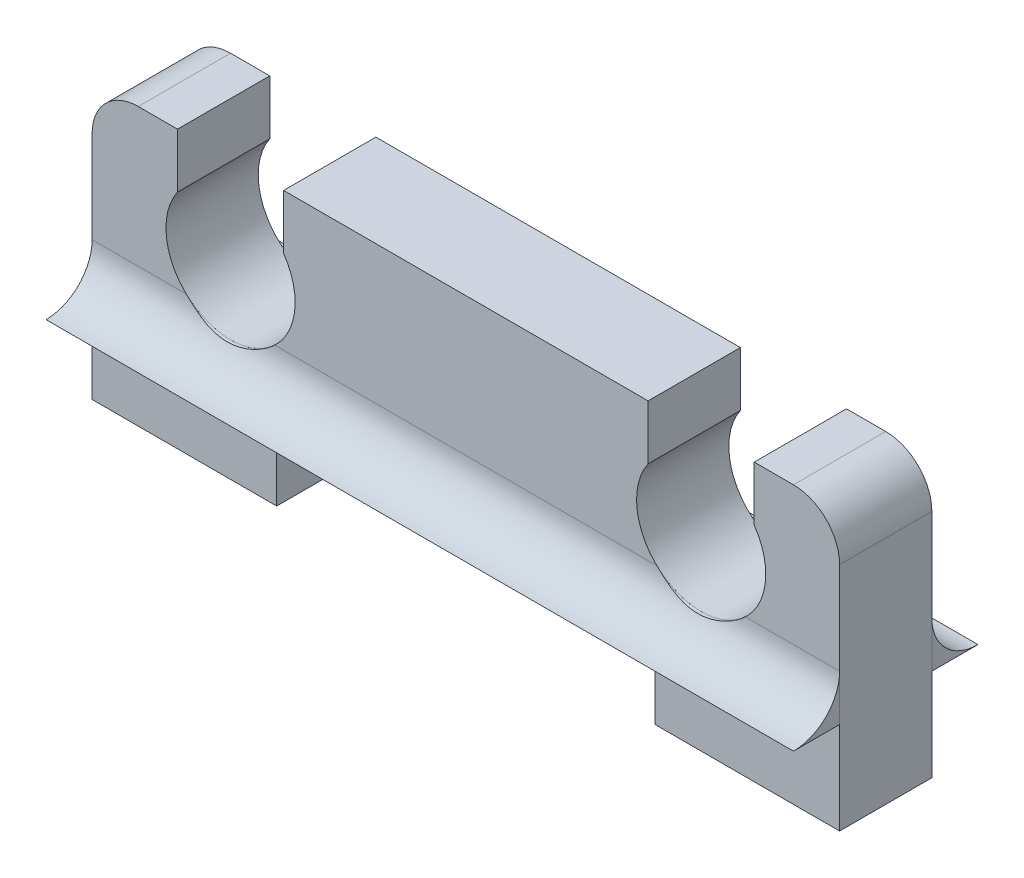
from build123d import *

# Parameters (mm, degrees)
BOSS_EXTRUDE1_DEPTH     = 2
BOSS_EXTRUDE2_DEPTH     = 16.2
BOSS_EXTRUDE2_2_DEPTH   = 16.2
SKETCH3_W               = 4
SKETCH3_H               = 2
CUT_EXTRUDE1_DEPTH      = 4
CUT_EXTRUDE4_START      = -1.18136
SKETCH5_W               = 2.3
SKETCH5_H               = 2
CUT_EXTRUDE4_DEPTH      = 1.18136
SKETCH8_R               = 1.4
CUT_EXTRUDE6_DEPTH      = 3
CUT_EXTRUDE6_DEPTH_BACK = 3


with BuildPart() as part:
    # Sketch1 → Boss-Extrude1 (new body)
    with BuildSketch(Plane.XY):
        with BuildLine():
            Line((4, 8), (12.2, 8))
            Line((12.2, 8), (12.2, 7))
            ThreePointArc((12.2, 7), (13.2, 4.620204103), (14.2, 7))
            Line((14.2, 7), (14.2, 8))
            Line((14.2, 8), (15.2, 8))
            ThreePointArc((15.2, 8), (15.907106781, 7.707106781), (16.2, 7))
            Line((16.2, 7), (16.2, 0))
            Line((16.2, 0), (12.2, 0))
            Line((12.2, 0), (12.2, 4))
            Line((12.2, 4), (4, 4))
            Line((4, 4), (4, 0))
            Line((4, 0), (0, 0))
            Line((0, 0), (0, 7))
            ThreePointArc((0, 7), (0.292893219, 7.707106781), (1, 8))
            Line((1, 8), (2, 8))
            Line((2, 8), (2, 7))
            ThreePointArc((2, 7), (3, 4.620204103), (4, 7))
            Line((4, 7), (4, 8))
        make_face()
    extrude(amount=BOSS_EXTRUDE1_DEPTH)

    # Sketch3 → Cut-Extrude1 (cut, through all)
    with BuildSketch(Plane.XY.offset(2)):
        with Locations((2, 1)):
            Rectangle(SKETCH3_W, SKETCH3_H)
        with Locations((14.2, 1)):
            Rectangle(SKETCH3_W, SKETCH3_H)
    extrude(amount=-CUT_EXTRUDE1_DEPTH, mode=Mode.SUBTRACT)

    # Sketch5 → Cut-Extrude4 (cut)
    with BuildSketch(Plane(origin=(0, 8, 0), x_dir=(1, 0, 0), z_dir=(0, 1, 0)).offset(CUT_EXTRUDE4_START)):
        with Locations((3, -1)):
            Rectangle(SKETCH5_W, SKETCH5_H)
        with Locations((13.2, -1)):
            Rectangle(SKETCH5_W, SKETCH5_H)
    extrude(amount=CUT_EXTRUDE4_DEPTH, mode=Mode.SUBTRACT)


with BuildPart() as body_2:
    # Sketch2 → Boss-Extrude2 (new body)
    with BuildSketch(Plane.ZY):
        with BuildLine():
            Line((2, 4), (2, 5))
            ThreePointArc((2, 5), (2.292893219, 4.292893219), (3, 4))
            Line((3, 4), (2, 4))
        make_face()
    extrude(amount=-BOSS_EXTRUDE2_DEPTH)


with BuildPart() as body_3:
    # Sketch2 → Boss-Extrude2 2 (new body)
    with BuildSketch(Plane.ZY):
        with BuildLine():
            Line((0, 4), (-1, 4))
            ThreePointArc((-1, 4), (-0.292893219, 4.292893219), (0, 5))
            Line((0, 5), (0, 4))
        make_face()
    extrude(amount=-BOSS_EXTRUDE2_2_DEPTH)


with BuildPart() as cut_extrude6_tool:
    # Sketch8 → Cut-Extrude6 (new body, two sides)
    with BuildSketch(Plane.XY.offset(1)) as cut_extrude6_sk:
        with Locations((3, 6.020204103)):
            Circle(SKETCH8_R)
        with Locations((13.2, 6.020204103)):
            Circle(SKETCH8_R)
    extrude(amount=CUT_EXTRUDE6_DEPTH)
    extrude(cut_extrude6_sk.sketch, amount=-CUT_EXTRUDE6_DEPTH_BACK)


with BuildPart() as body_2_1:
    add(body_2.part)

    # Cut-Extrude6: cut by cut_extrude6_tool
    add(cut_extrude6_tool.part, mode=Mode.SUBTRACT)


with BuildPart() as body_3_1:
    add(body_3.part)

    # Cut-Extrude6: cut by cut_extrude6_tool
    add(cut_extrude6_tool.part, mode=Mode.SUBTRACT)


solid = Compound([part.part, body_2_1.part, body_3_1.part])
